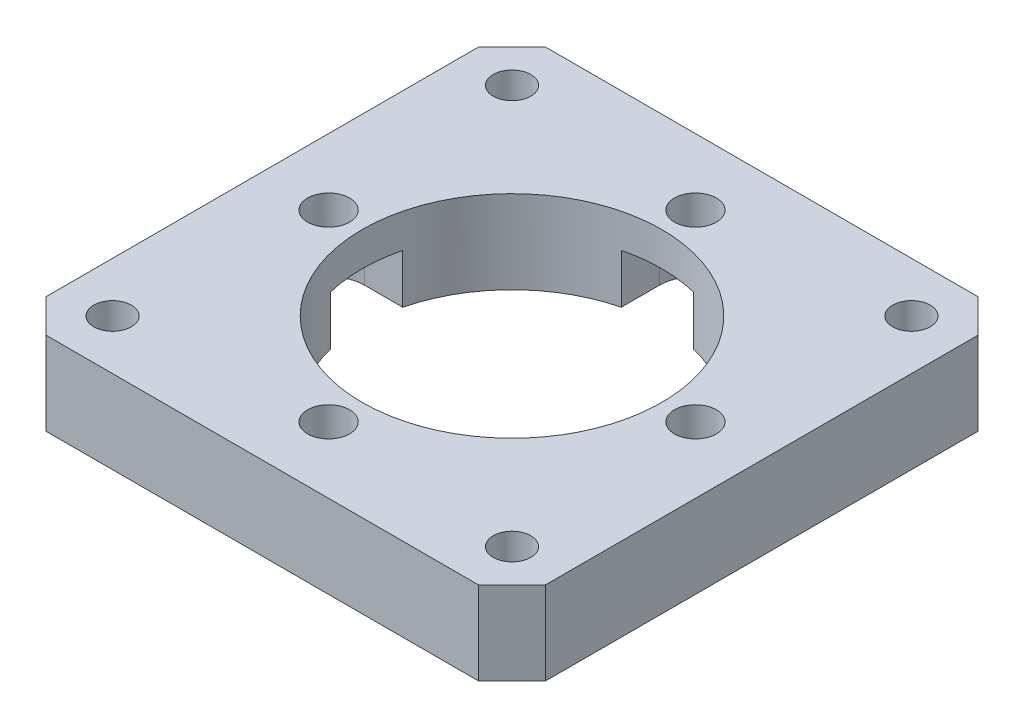
from build123d import *

# Parameters (mm, degrees)
SKETCH1_W           = 38.1
SKETCH1_H           = 38.1
SKETCH1_R           = 11.43
BOSS_EXTRUDE1_DEPTH = 6.35
SKETCH2_R           = 1.6002
SKETCH2_R_2         = 1.4351
CUT_EXTRUDE1_DEPTH  = 7.35
CIRPATTERN1_COUNT   = 4
CHAMFER1_SIZE       = 2.54
CUT_EXTRUDE2_DEPTH  = 3.7592
CIRPATTERN4_COUNT   = 4


with BuildPart() as part:
    # Sketch1 → Boss-Extrude1 (new body)
    with BuildSketch(Plane(origin=(0, 0, 0), x_dir=(1, 0, 0), z_dir=(0, 1, 0))):
        Rectangle(SKETCH1_W, SKETCH1_H)
        Circle(SKETCH1_R, mode=Mode.SUBTRACT)
    extrude(amount=BOSS_EXTRUDE1_DEPTH)

    # Sketch2 → Cut-Extrude1 (cut, through all)
    with BuildSketch(Plane(origin=(0, 6.35, 0), x_dir=(1, 0, 0), z_dir=(0, 1, 0))):
        with Locations((0, 13.9954)):
            Circle(SKETCH2_R)
        with Locations((15.24, 15.24)):
            Circle(SKETCH2_R_2)
    cut_extrude1 = extrude(amount=-CUT_EXTRUDE1_DEPTH, mode=Mode.SUBTRACT)

    # CirPattern1: Cut-Extrude1 ×4 about axis
    cirpattern1_axis = Axis((0, 0, 0), (0, 1, 0))
    for i in range(1, CIRPATTERN1_COUNT):
        add(cut_extrude1.rotate(cirpattern1_axis, i * 360 / CIRPATTERN1_COUNT), mode=Mode.SUBTRACT)

    # Chamfer1
    chamfer1_edges = [part.edges().sort_by_distance(p)[0] for p in [
        (19.05, 3.175, 19.05),
        (-19.05, 3.175, 19.05),
        (-19.05, 3.175, -19.05),
        (19.05, 3.175, -19.05),
    ]]
    chamfer(chamfer1_edges, length=CHAMFER1_SIZE)

    # Sketch3 → Cut-Extrude2 (cut)
    with BuildSketch(Plane.XZ):
        with BuildLine():
            Line((2.7559, 13.9954), (2.7559, 0))
            ThreePointArc((2.7559, 0), (0, -2.7559), (-2.7559, 0))
            Line((-2.7559, 0), (-2.7559, 13.9954))
            ThreePointArc((-2.7559, 13.9954), (0, 16.7513), (2.7559, 13.9954))
        make_face()
    cut_extrude2 = extrude(amount=-CUT_EXTRUDE2_DEPTH, mode=Mode.SUBTRACT)

    # CirPattern4: Cut-Extrude2 ×4 about axis
    cirpattern4_axis = Axis((0, 0, 0), (0, 1, 0))
    for i in range(1, CIRPATTERN4_COUNT):
        add(cut_extrude2.rotate(cirpattern4_axis, i * 360 / CIRPATTERN4_COUNT), mode=Mode.SUBTRACT)


solid = part.part
